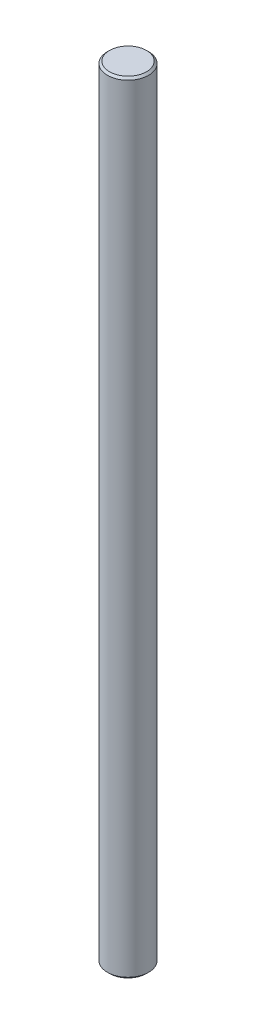
from build123d import *


with BuildPart() as part:
    # Sketch1 → Revolve1 (revolve)
    with BuildSketch(Plane.XY.offset(4.935145608)):
        Polygon((-1.144407818, 12.612134029), (-2.044407818, 12.612134029), (-2.044407818, -25.387865971), (-1.144407818, -25.387865971), (-1.044407818, -25.287865971), (-1.044407818, 12.512134029), align=None)
    revolve(axis=Axis((-2.044407818, 12.612134029, 4.935145608), (0, -1, 0)))


solid = part.part
